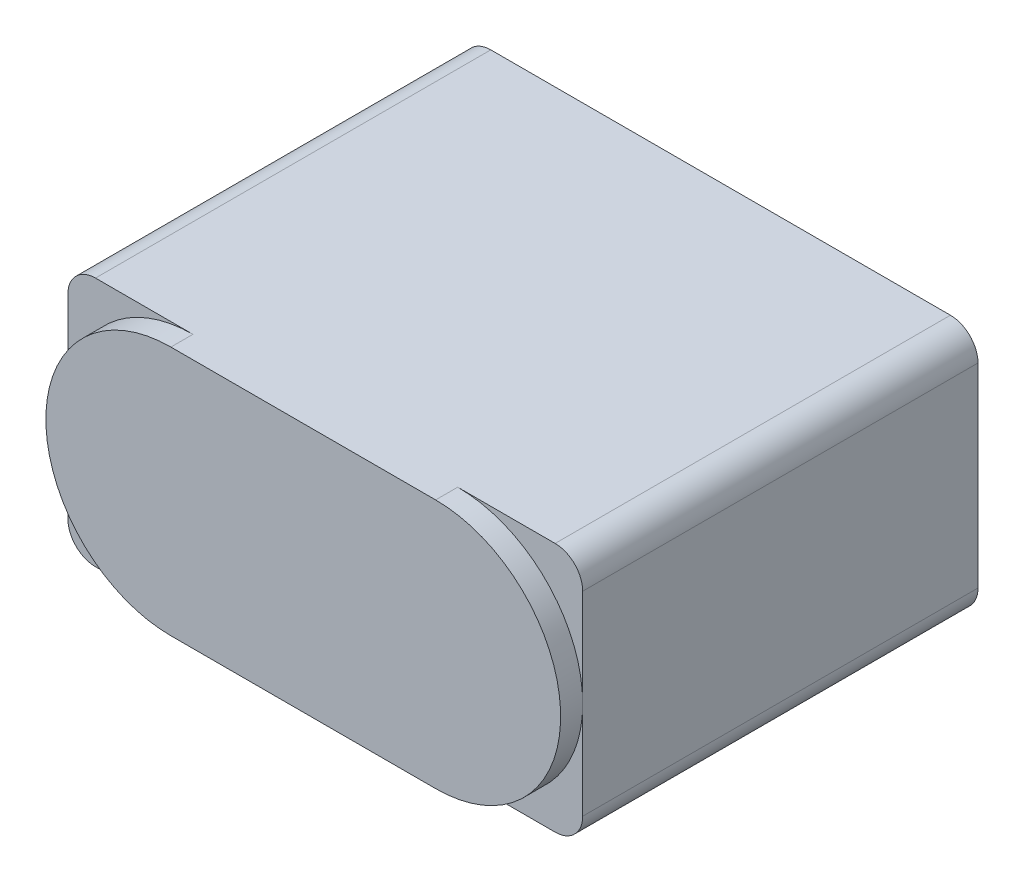
from build123d import *

# Parameters (mm, degrees)
EXTRUDE_1_DEPTH     = 22.7
CUT_EXTRUDE_1_DEPTH = 1.2
SKETCH_3_R          = 1.25
SKETCH_3_W          = 8
SKETCH_3_H          = 6
CUT_EXTRUDE_2_DEPTH = 5
SKETCH_4_R          = 0.75
CUT_EXTRUDE_3_DEPTH = 5


with BuildPart() as part:
    # 草图1 → 凸台-拉伸1 (new body)
    with BuildSketch(Plane.XY):
        with BuildLine():
            Line((1.5, 0), (26.5, 0))
            ThreePointArc((26.5, 0), (27.560660172, 0.439339828), (28, 1.5))
            Line((28, 1.5), (28, 12.1))
            ThreePointArc((28, 12.1), (27.560660172, 13.160660172), (26.5, 13.6))
            Line((26.5, 13.6), (1.5, 13.6))
            ThreePointArc((1.5, 13.6), (0.439339828, 13.160660172), (0, 12.1))
            Line((0, 12.1), (0, 1.5))
            ThreePointArc((0, 1.5), (0.439339828, 0.439339828), (1.5, 0))
        make_face()
    extrude(amount=EXTRUDE_1_DEPTH)

    # 草图2 → 切除-拉伸1 (cut)
    with BuildSketch(Plane.XY.offset(22.7)):
        with BuildLine():
            ThreePointArc((0, 6.800000018), (1.991673894, 11.608326118), (6.8, 13.6))
            Line((6.8, 13.6), (1.5, 13.6))
            ThreePointArc((1.5, 13.6), (0.439339828, 13.160660172), (0, 12.1))
            Line((0, 12.1), (0, 6.800000018))
        make_face()
        with BuildLine():
            ThreePointArc((6.8, 0), (1.991673882, 1.991673894), (0, 6.800000018))
            Line((0, 6.800000018), (0, 1.5))
            ThreePointArc((0, 1.5), (0.439339828, 0.439339828), (1.5, 0))
            Line((1.5, 0), (6.8, 0))
        make_face()
        with BuildLine():
            Line((28, 1.5), (28, 6.8))
            ThreePointArc((28, 6.8), (26.008326112, 1.991673888), (21.2, 0))
            Line((21.2, 0), (26.5, 0))
            ThreePointArc((26.5, 0), (27.560660172, 0.439339828), (28, 1.5))
        make_face()
        with BuildLine():
            Line((26.5, 13.6), (21.2, 13.6))
            ThreePointArc((21.2, 13.6), (26.008326112, 11.608326112), (28, 6.8))
            Line((28, 6.8), (28, 12.1))
            ThreePointArc((28, 12.1), (27.560660172, 13.160660172), (26.5, 13.6))
        make_face()
    extrude(amount=-CUT_EXTRUDE_1_DEPTH, mode=Mode.SUBTRACT)

    # 草图3 → 切除-拉伸2 (cut)
    with BuildSketch(Plane(origin=(0, 0, 0), x_dir=(-1, 0, 0), z_dir=(0, 0, -1))):
        with Locations((-24.8, 6.8)):
            Circle(SKETCH_3_R)
        with Locations((-3.2, 6.8)):
            Circle(SKETCH_3_R)
        with Locations((-14, 6.8)):
            Rectangle(SKETCH_3_W, SKETCH_3_H)
    extrude(amount=-CUT_EXTRUDE_2_DEPTH, mode=Mode.SUBTRACT)

    # 草图4 → 切除-拉伸3 (cut)
    with BuildSketch(Plane.XZ):
        with Locations((24.8, 11.6)):
            Circle(SKETCH_4_R)
        with Locations((3.2, 11.6)):
            Circle(SKETCH_4_R)
    extrude(amount=-CUT_EXTRUDE_3_DEPTH, mode=Mode.SUBTRACT)


solid = part.part
